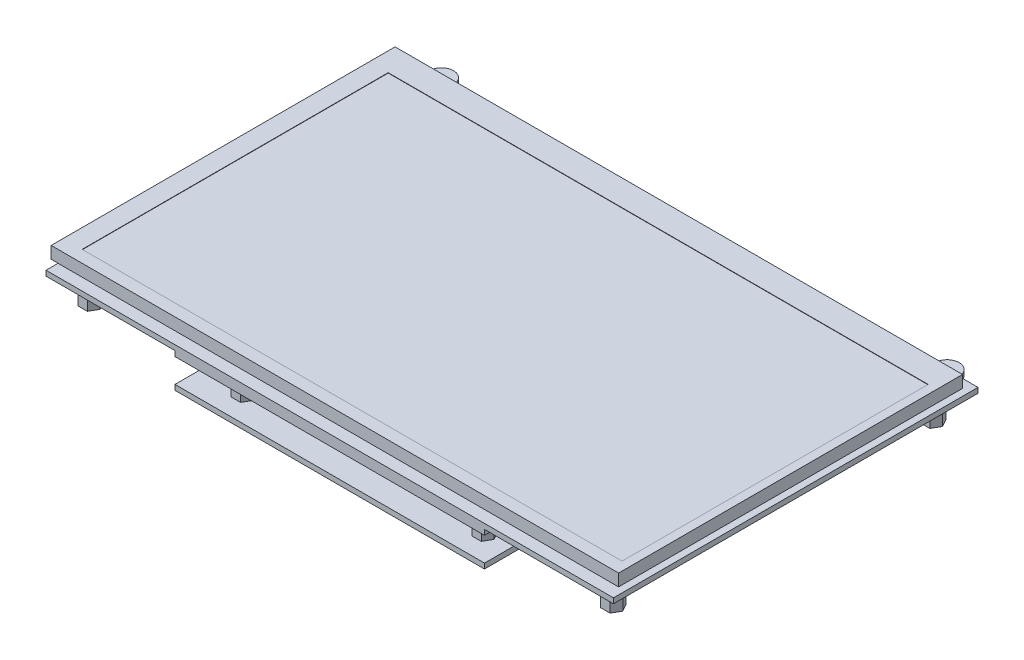
from build123d import *

# Parameters (mm, degrees)
SKETCH_1_W          = 165
SKETCH_1_H          = 100
EXTRUDE_1_DEPTH     = 3.5
SKETCH_2_W          = 35
SKETCH_2_H          = 12
SKETCH_2_W_2        = 5
SKETCH_2_H_2        = 80
SKETCH_2_W_3        = 30
EXTRUDE_2_DEPTH     = 2
EXTRUDE_3_DEPTH     = 1.5
SKETCH_4_W          = 90
SKETCH_4_H          = 64
EXTRUDE_4_DEPTH     = 1.5
SKETCH_5_R          = 1.5
EXTRUDE_5_DEPTH     = 7
SKETCH_6_W          = 90
SKETCH_6_H          = 64
SKETCH_6_W_2        = 6.8
SKETCH_6_H_2        = 16
SKETCH_6_H_3        = 10.5
SKETCH_6_H_4        = 8.5
SKETCH_6_W_3        = 5
SKETCH_6_H_5        = 2.5
EXTRUDE_6_DEPTH     = 1.5
SKETCH_7_R          = 1.5
EXTRUDE_7_DEPTH     = 7
SKETCH_8_W          = 157
SKETCH_8_H          = 89
CUT_EXTRUDE_1_DEPTH = 0.1


with BuildPart() as part:
    # 草图1 → 凸台-拉伸1 (new body)
    with BuildSketch(Plane(origin=(0, 0, 0), x_dir=(1, 0, 0), z_dir=(0, 1, 0))):
        Rectangle(SKETCH_1_W, SKETCH_1_H)
    extrude(amount=EXTRUDE_1_DEPTH)

    # 草图2 → 凸台-拉伸2 (add)
    with BuildSketch(Plane.XZ):
        with Locations((0, 39)):
            Rectangle(SKETCH_2_W, SKETCH_2_H)
        with Locations((-75, 0)):
            Rectangle(SKETCH_2_W_2, SKETCH_2_H_2)
        with Locations((75, 0)):
            Rectangle(SKETCH_2_W_2, SKETCH_2_H_2)
        with Locations((-42.5, -39)):
            Rectangle(SKETCH_2_W_3, SKETCH_2_H)
    extrude(amount=EXTRUDE_2_DEPTH)

    # 草图3 → 凸台-拉伸3 (add)
    with BuildSketch(Plane.XZ.offset(2)):
        with BuildLine():
            Line((82.5, -54.5), (77, -54.5))
            ThreePointArc((77, -54.5), (73.5, -58), (70, -54.5))
            Line((70, -54.5), (-70, -54.5))
            ThreePointArc((-70, -54.5), (-73.5, -58), (-77, -54.5))
            Line((-77, -54.5), (-82.5, -54.5))
            Line((-82.5, -54.5), (-82.5, 51.5))
            Line((-82.5, 51.5), (82.5, 51.5))
            Line((82.5, 51.5), (82.5, -54.5))
        make_face()
    extrude(amount=EXTRUDE_3_DEPTH)

    # 草图4 → 凸台-拉伸4 (add)
    with BuildSketch(Plane.XZ.offset(3.5)):
        with Locations((0, 19.5)):
            Rectangle(SKETCH_4_W, SKETCH_4_H)
    extrude(amount=EXTRUDE_4_DEPTH)

    # 草图5 → 凸台-拉伸5 (add)
    with BuildSketch(Plane.XZ.offset(5)):
        Polygon((-33.643226867, 46.5), (-30.929680602, 46.5), (-29.57290747, 44.15), (-30.929680602, 41.8), (-33.643226867, 41.8), (-35, 44.15), align=None)
        with Locations((-32.286453735, 44.15)):
            Circle(SKETCH_5_R, mode=Mode.SUBTRACT)
        Polygon((35, 44.15), (36.356773133, 46.5), (39.070319398, 46.5), (40.42709253, 44.15), (39.070319398, 41.8), (36.356773133, 41.8), align=None)
        with Locations((37.713546265, 44.15)):
            Circle(SKETCH_5_R, mode=Mode.SUBTRACT)
        Polygon((36.356773133, -2.8), (35, -5.15), (36.356773133, -7.5), (39.070319398, -7.5), (40.42709253, -5.15), (39.070319398, -2.8), align=None)
        with Locations((37.713546265, -5.15)):
            Circle(SKETCH_5_R, mode=Mode.SUBTRACT)
        Polygon((-33.643226867, -2.8), (-35, -5.15), (-33.643226867, -7.5), (-30.929680602, -7.5), (-29.57290747, -5.15), (-30.929680602, -2.8), align=None)
        with Locations((-32.286453735, -5.15)):
            Circle(SKETCH_5_R, mode=Mode.SUBTRACT)
    extrude(amount=EXTRUDE_5_DEPTH)

    # 草图6 → 凸台-拉伸6 (add)
    with BuildSketch(Plane.XZ.offset(12)):
        with Locations((0, 19.5)):
            Rectangle(SKETCH_6_W, SKETCH_6_H)
        with Locations((-39.1, 35.5)):
            Rectangle(SKETCH_6_W_2, SKETCH_6_H_2, mode=Mode.SUBTRACT)
        with Locations((-39.1, 19.25)):
            Rectangle(SKETCH_6_W_2, SKETCH_6_H_3, mode=Mode.SUBTRACT)
        with Locations((-39.1, 6.25)):
            Rectangle(SKETCH_6_W_2, SKETCH_6_H_3, mode=Mode.SUBTRACT)
        with Locations((-39.1, -5.25)):
            Rectangle(SKETCH_6_W_2, SKETCH_6_H_4, mode=Mode.SUBTRACT)
        with Locations((31.412593709, 19.5)):
            Rectangle(SKETCH_6_W_3, SKETCH_6_H_5, mode=Mode.SUBTRACT)
    extrude(amount=EXTRUDE_6_DEPTH)

    # 草图7 → 凸台-拉伸7 (add)
    with BuildSketch(Plane.XZ.offset(3.5)):
        Polygon((-77.356773133, 47.35), (-74.643226867, 47.35), (-73.286453735, 45), (-74.643226867, 42.65), (-77.356773133, 42.65), (-78.713546265, 45), align=None)
        with Locations((-76, 45)):
            Circle(SKETCH_7_R, mode=Mode.SUBTRACT)
        Polygon((73.286453735, 45), (74.643226867, 47.35), (77.356773133, 47.35), (78.713546265, 45), (77.356773133, 42.65), (74.643226867, 42.65), align=None)
        with Locations((76, 45)):
            Circle(SKETCH_7_R, mode=Mode.SUBTRACT)
        Polygon((74.643226867, -45.65), (73.286453735, -48), (74.643226867, -50.35), (77.356773133, -50.35), (78.713546265, -48), (77.356773133, -45.65), align=None)
        with Locations((76, -48)):
            Circle(SKETCH_7_R, mode=Mode.SUBTRACT)
        Polygon((-77.356773133, -45.65), (-78.713546265, -48), (-77.356773133, -50.35), (-74.643226867, -50.35), (-73.286453735, -48), (-74.643226867, -45.65), align=None)
        with Locations((-76, -48)):
            Circle(SKETCH_7_R, mode=Mode.SUBTRACT)
    extrude(amount=EXTRUDE_7_DEPTH)

    # 草图8 → 切除-拉伸1 (cut)
    with BuildSketch(Plane(origin=(0, 3.5, 0), x_dir=(1, 0, 0), z_dir=(0, 1, 0))):
        with Locations((1.5, -2)):
            Rectangle(SKETCH_8_W, SKETCH_8_H)
    extrude(amount=-CUT_EXTRUDE_1_DEPTH, mode=Mode.SUBTRACT)


solid = part.part
